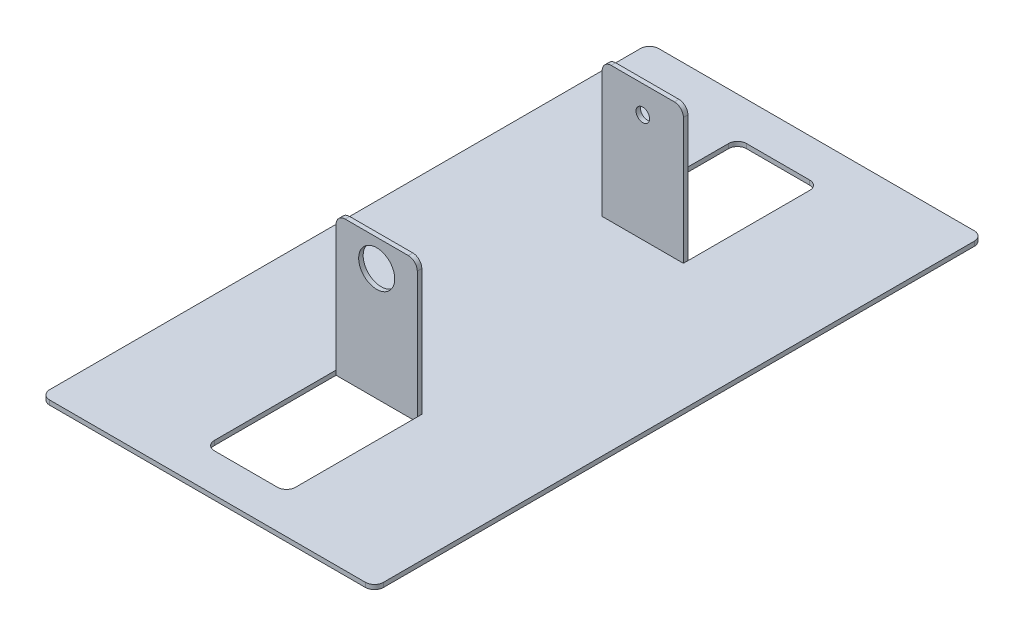
from build123d import *

# Parameters (mm, degrees)
SKETCH1_W           = 74
SKETCH1_H           = 135
SKETCH1_W_2         = 18
SKETCH1_H_2         = 30
BOSS_EXTRUDE1_DEPTH = 1
BOSS_EXTRUDE2_START = -1
SKETCH2_W           = 18
SKETCH2_H           = 1
BOSS_EXTRUDE2_DEPTH = 31
CUT_EXTRUDE3_REACH  = 99.5
SKETCH5_R           = 4
CUT_EXTRUDE4_REACH  = 40.5
SKETCH6_R           = 1.5
FILLET2_R           = 2


with BuildPart() as part:
    # Sketch1 → Boss-Extrude1 (new body)
    with BuildSketch(Plane(origin=(0, 0, 0), x_dir=(1, 0, 0), z_dir=(0, 1, 0))):
        Rectangle(SKETCH1_W, SKETCH1_H)
        with Locations((0, 44)):
            Rectangle(SKETCH1_W_2, SKETCH1_H_2, mode=Mode.SUBTRACT)
        with Locations((0, -44)):
            Rectangle(SKETCH1_W_2, SKETCH1_H_2, mode=Mode.SUBTRACT)
    extrude(amount=BOSS_EXTRUDE1_DEPTH)

    # Sketch2 → Boss-Extrude2 (add)
    with BuildSketch(Plane(origin=(0, 1, 0), x_dir=(1, 0, 0), z_dir=(0, 1, 0)).offset(BOSS_EXTRUDE2_START)):
        with Locations((0, 29.5)):
            Rectangle(SKETCH2_W, SKETCH2_H)
        with Locations((0, -29.5)):
            Rectangle(SKETCH2_W, SKETCH2_H)
    extrude(amount=BOSS_EXTRUDE2_DEPTH)

    # Sketch5 → Cut-Extrude3 (cut, up to next)
    with BuildSketch(Plane.XY.offset(30), mode=Mode.PRIVATE) as cut_extrude3_sk1:
        with Locations((0, 25)):
            Circle(SKETCH5_R)
    cut_extrude3_tool1 = extrude(cut_extrude3_sk1.sketch, amount=-CUT_EXTRUDE3_REACH, mode=Mode.PRIVATE) & part.part
    add(cut_extrude3_tool1.solids().sort_by_distance((0, 25, 30))[0], mode=Mode.SUBTRACT)

    # Sketch6 → Cut-Extrude4 (cut, up to next)
    with BuildSketch(Plane.XY.offset(-29), mode=Mode.PRIVATE) as cut_extrude4_sk1:
        with Locations((0, 25)):
            Circle(SKETCH6_R)
    cut_extrude4_tool1 = extrude(cut_extrude4_sk1.sketch, amount=-CUT_EXTRUDE4_REACH, mode=Mode.PRIVATE) & part.part
    add(cut_extrude4_tool1.solids().sort_by_distance((0, 25, -29))[0], mode=Mode.SUBTRACT)

    # Fillet2
    fillet2_edges = [part.edges().sort_by_distance(p)[0] for p in [
        (9, 0.5, -59),
        (-9, 0.5, -59),
        (-9, 0.5, 59),
        (9, 0.5, 59),
        (-9, 31, -29.5),
        (9, 31, -29.5),
        (-9, 31, 29.5),
        (9, 31, 29.5),
        (37, 0.5, 67.5),
        (-37, 0.5, 67.5),
        (-37, 0.5, -67.5),
        (37, 0.5, -67.5),
    ]]
    fillet(fillet2_edges, radius=FILLET2_R)


solid = part.part
